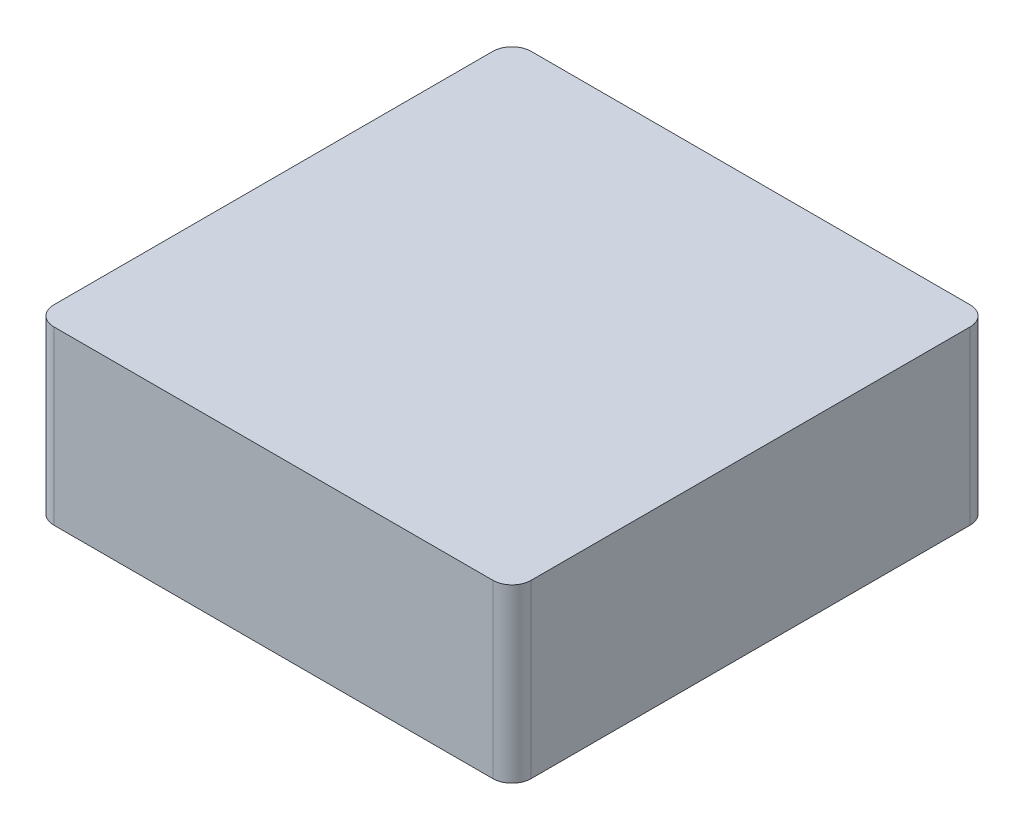
from build123d import *

# Parameters (mm, degrees)
SKETCH1_W           = 25
SKETCH1_H           = 25
BOSS_EXTRUDE1_DEPTH = 9
FILLET1_R           = 1


with BuildPart() as part:
    # Sketch1 → Boss-Extrude1 (new body)
    with BuildSketch(Plane(origin=(0, 0, 0), x_dir=(1, 0, 0), z_dir=(0, 1, 0))):
        Rectangle(SKETCH1_W, SKETCH1_H)
    extrude(amount=BOSS_EXTRUDE1_DEPTH)

    # Fillet1
    fillet1_edges = [part.edges().sort_by_distance(p)[0] for p in [
        (-12.5, 4.5, -12.5),
        (12.5, 4.5, -12.5),
        (12.5, 4.5, 12.5),
        (-12.5, 4.5, 12.5),
    ]]
    fillet(fillet1_edges, radius=FILLET1_R)


solid = part.part
